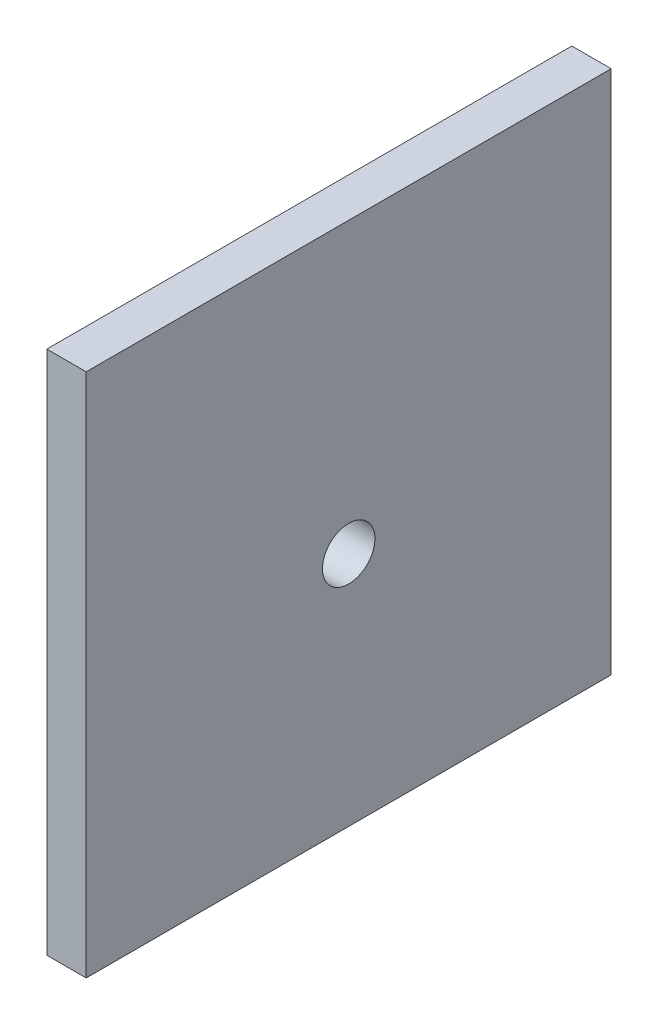
from build123d import *

# Parameters (mm, degrees)
CROQUIS1_W              = 40
CROQUIS1_H              = 40
CROQUIS1_R              = 2
SALIENTE_EXTRUIR1_DEPTH = 3


with BuildPart() as part:
    # Croquis1 → Saliente-Extruir1 (new body)
    with BuildSketch(Plane(origin=(0, 0, 0), x_dir=(0, 0, -1), z_dir=(1, 0, 0))):
        with Locations((-11.269245759, -12.197301292)):
            Rectangle(CROQUIS1_W, CROQUIS1_H)
        with Locations((-11.269245759, -14.197301292)):
            Circle(CROQUIS1_R, mode=Mode.SUBTRACT)
    extrude(amount=SALIENTE_EXTRUIR1_DEPTH)


solid = part.part
